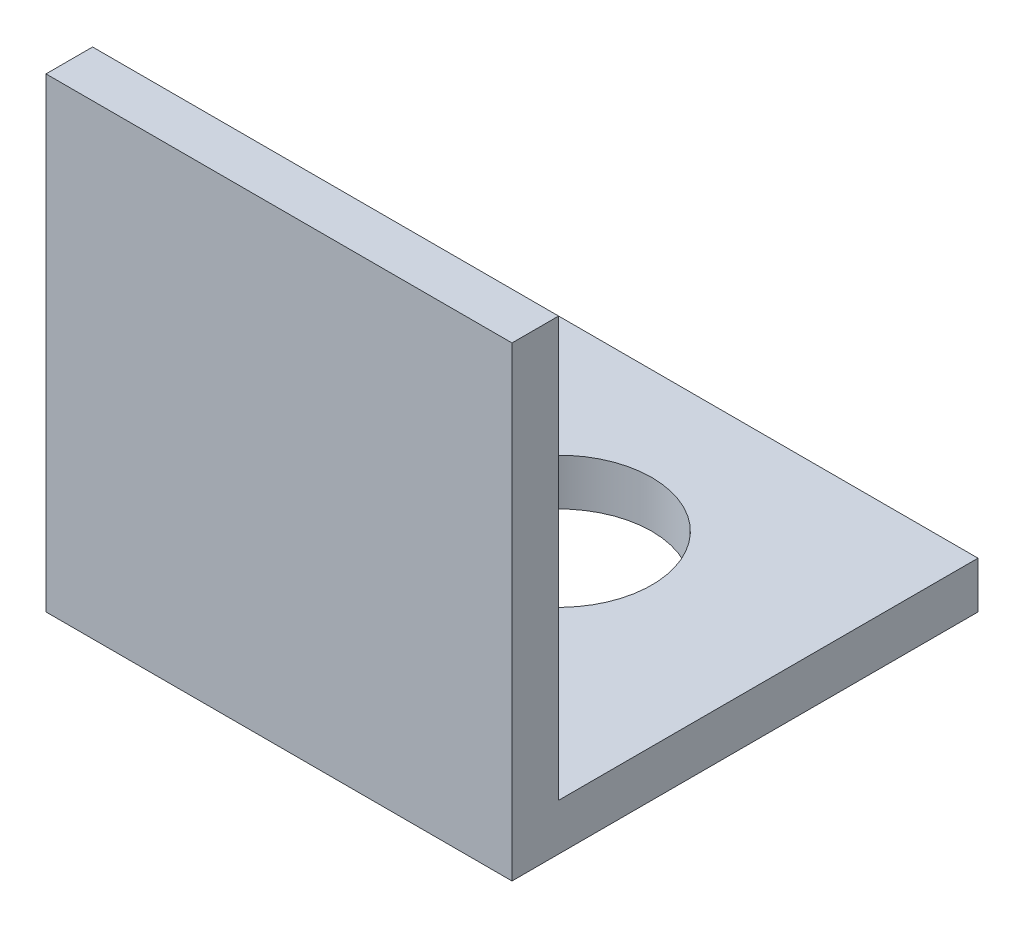
from build123d import *

# Parameters (mm, degrees)
EXTRUDE_1_DEPTH     = 30
SKETCH_2_R          = 6
CUT_EXTRUDE_1_DEPTH = 31


with BuildPart() as part:
    # Эскиз1 → Вытянуть-Тонкостенный1 (new body)
    with BuildSketch(Plane(origin=(0, 0, 0), x_dir=(0, 0, -1), z_dir=(1, 0, 0))):
        Polygon((0, 30), (0, 0), (30, 0), (30, 3), (3, 3), (3, 30), align=None)
    extrude(amount=EXTRUDE_1_DEPTH)

    # Эскиз2 → Вырез-Вытянуть1 (cut, through all)
    with BuildSketch(Plane.XZ):
        with Locations((15, -18)):
            Circle(SKETCH_2_R)
    extrude(amount=-CUT_EXTRUDE_1_DEPTH, mode=Mode.SUBTRACT)


solid = part.part
